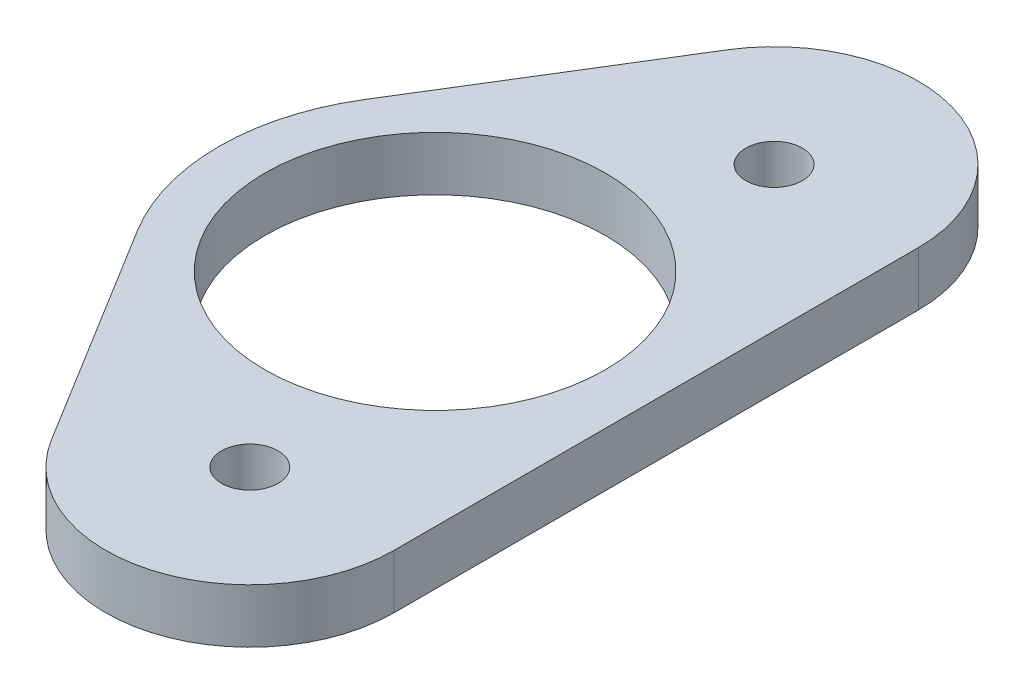
from build123d import *

# Parameters (mm, degrees)
SKETCH1_R           = 15
SKETCH1_R_2         = 2.4892
BOSS_EXTRUDE1_DEPTH = 4.7625


with BuildPart() as part:
    # Sketch1 → Boss-Extrude1 (new body)
    with BuildSketch(Plane(origin=(0, 0, 0), x_dir=(1, 0, 0), z_dir=(0, 1, 0))):
        with BuildLine():
            Line((-66.545030839, 29.74801255), (-78.71799706, 9.993951739))
            ThreePointArc((-78.71799706, 9.993951739), (-81.55, 0), (-78.71799706, -9.993951739))
            Line((-78.71799706, -9.993951739), (-66.545030839, -29.74801255))
            ThreePointArc((-66.545030839, -29.74801255), (-52.270546345, -35.304264568), (-43.033032799, -23.085378057))
            Line((-43.033032799, -23.085378057), (-43.033032799, 23.085378057))
            ThreePointArc((-43.033032799, 23.085378057), (-52.270546345, 35.304264568), (-66.545030839, 29.74801255))
        make_face()
        with Locations((-62.5, 0)):
            Circle(SKETCH1_R, mode=Mode.SUBTRACT)
        with Locations((-55.733032799, 23.085378057)):
            Circle(SKETCH1_R_2, mode=Mode.SUBTRACT)
        with Locations((-55.733032799, -23.085378057)):
            Circle(SKETCH1_R_2, mode=Mode.SUBTRACT)
    extrude(amount=BOSS_EXTRUDE1_DEPTH)


solid = part.part
